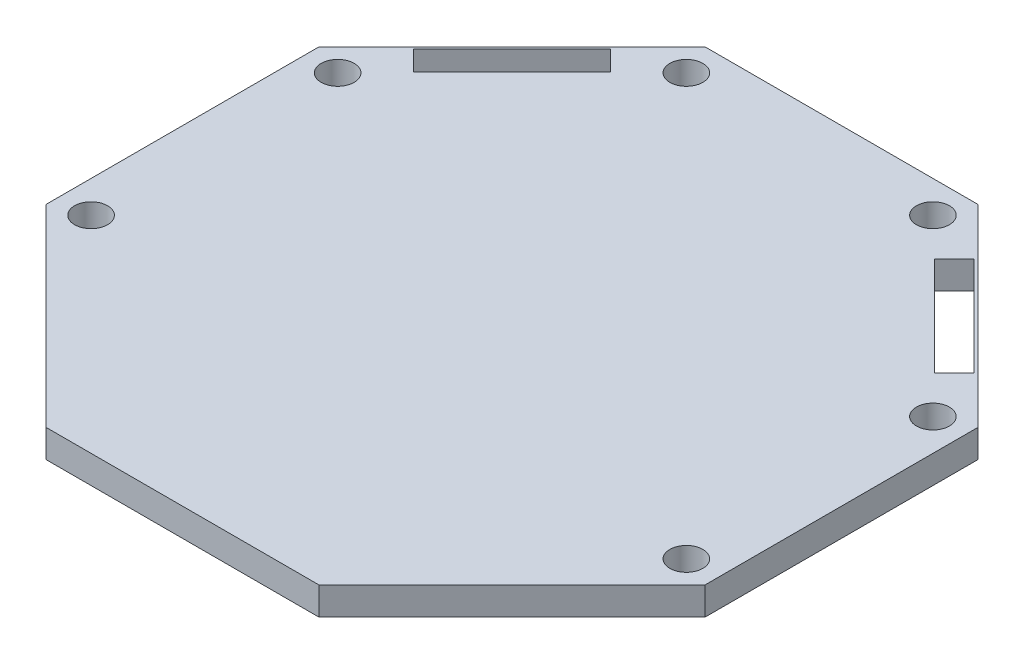
from build123d import *

# Parameters (mm, degrees)
BOSS_EXTRUDE1_DEPTH       = 2.54
F_3_0MM_DOWEL_HOLE1_D     = 3
F_3_0MM_DOWEL_HOLE1_DEPTH = 7.999984
F_3_0MM_DOWEL_HOLE1_TIP   = 0.901290929


with BuildPart() as part:
    # Sketch1 → Boss-Extrude1 (new body)
    with BuildSketch(Plane(origin=(0, 0, 0), x_dir=(1, 0, 0), z_dir=(0, 1, 0))):
        Polygon((59.944, 42.386808891), (42.386808891, 59.944), (17.557191109, 59.944), (0, 42.386808891), (0, 17.557191109), (17.557191109, 0), (42.386808891, 0), (59.944, 17.557191109), align=None)
        Polygon((4.468072616, 46.495671263), (6.26412384, 44.699620039), (15.244379961, 53.67987616), (13.448328737, 55.475927384), align=None, mode=Mode.SUBTRACT)
        Polygon((53.67987616, 44.699620039), (44.699620039, 53.67987616), (46.495671263, 55.475927384), (55.475927384, 46.495671263), align=None, mode=Mode.SUBTRACT)
    extrude(amount=BOSS_EXTRUDE1_DEPTH)

    # Ø3.0mm Dowel Hole1
    with Locations(Plane(origin=(0, 2.54, 0), x_dir=(1, 0, 0), z_dir=(0, 1, 0))):
        with Locations((2.9, 18.758410439), (57.044, 18.758410439), (2.9, 41.18558956), (57.044, 41.185589561), (18.758410439, 57.044), (41.185589561, 57.044)):
            Hole(F_3_0MM_DOWEL_HOLE1_D / 2, depth=F_3_0MM_DOWEL_HOLE1_DEPTH)
            with Locations((0, 0, -(F_3_0MM_DOWEL_HOLE1_DEPTH + F_3_0MM_DOWEL_HOLE1_TIP / 2))):  # 118° drill point
                Cone(0, F_3_0MM_DOWEL_HOLE1_D / 2, F_3_0MM_DOWEL_HOLE1_TIP, mode=Mode.SUBTRACT)


solid = part.part
